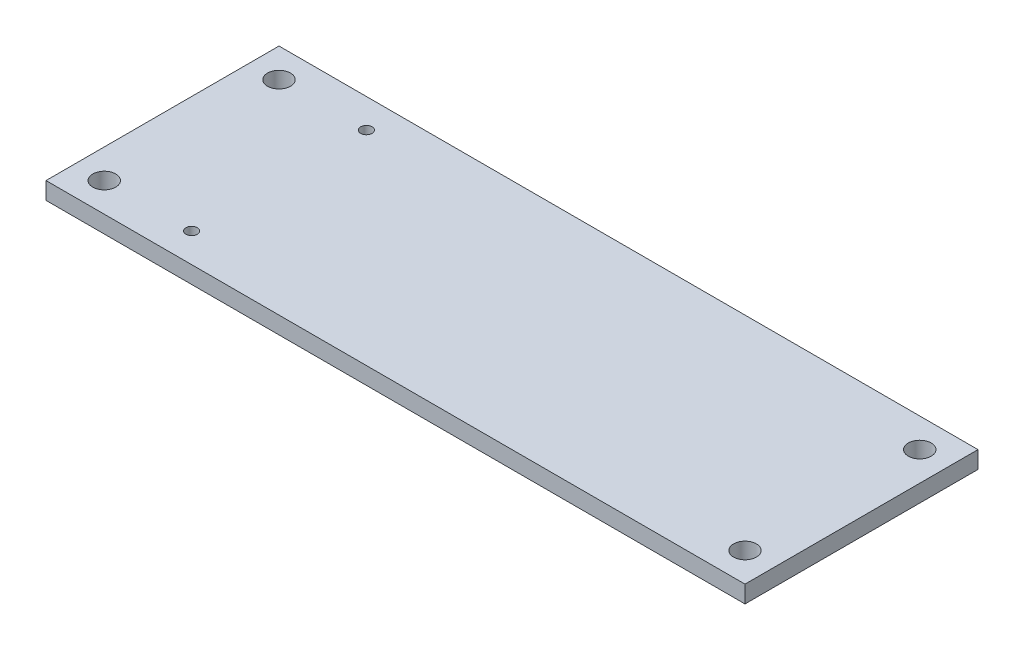
from build123d import *

# Parameters (mm, degrees)
SKETCH1_W           = 60.96
SKETCH1_H           = 20.32
SKETCH1_R           = 1
SKETCH1_R_2         = 0.5
BOSS_EXTRUDE1_DEPTH = 1.5
SKETCH1_3_R         = 0.5
CUT_EXTRUDE3_DEPTH  = 0.03


with BuildPart() as part:
    # Sketch1 → Boss-Extrude1 (new body)
    with BuildSketch(Plane(origin=(0, 0, 0), x_dir=(1, 0, 0), z_dir=(0, 1, 0))):
        with Locations((30.48, 10.16)):
            Rectangle(SKETCH1_W, SKETCH1_H)
        with Locations(Location((2.54, 2.54, 0), (0, 0, 270))):  # turned: the seam where the file's is
            Circle(SKETCH1_R, mode=Mode.SUBTRACT)
        with Locations(Location((58.42, 2.54, 0), (0, 0, 270))):  # turned: the seam where the file's is
            Circle(SKETCH1_R, mode=Mode.SUBTRACT)
        with Locations(Location((58.42, 17.78, 0), (0, 0, 270))):  # turned: the seam where the file's is
            Circle(SKETCH1_R, mode=Mode.SUBTRACT)
        with Locations(Location((2.54, 17.78, 0), (0, 0, 270))):  # turned: the seam where the file's is
            Circle(SKETCH1_R, mode=Mode.SUBTRACT)
        with Locations(Location((10.16, 2.54, 0), (0, 0, 270))):  # turned: the seam where the file's is
            Circle(SKETCH1_R_2, mode=Mode.SUBTRACT)
        with Locations(Location((10.16, 17.78, 0), (0, 0, 270))):  # turned: the seam where the file's is
            Circle(SKETCH1_R_2, mode=Mode.SUBTRACT)
    extrude(amount=BOSS_EXTRUDE1_DEPTH)

    # Sketch1_3 → Cut-Extrude3 (cut)
    with BuildSketch(Plane(origin=(0, 0, 0), x_dir=(1, 0, 0), z_dir=(0, 1, 0))):
        with Locations(Location((53.34, 8.57, 0), (0, 0, 270))):  # turned: the seam where the file's is
            Circle(SKETCH1_3_R)
        with Locations(Location((53.34, 11.11, 0), (0, 0, 90))):  # turned: the seam where the file's is
            Circle(SKETCH1_3_R)
    extrude(amount=CUT_EXTRUDE3_DEPTH, mode=Mode.SUBTRACT)


solid = part.part
